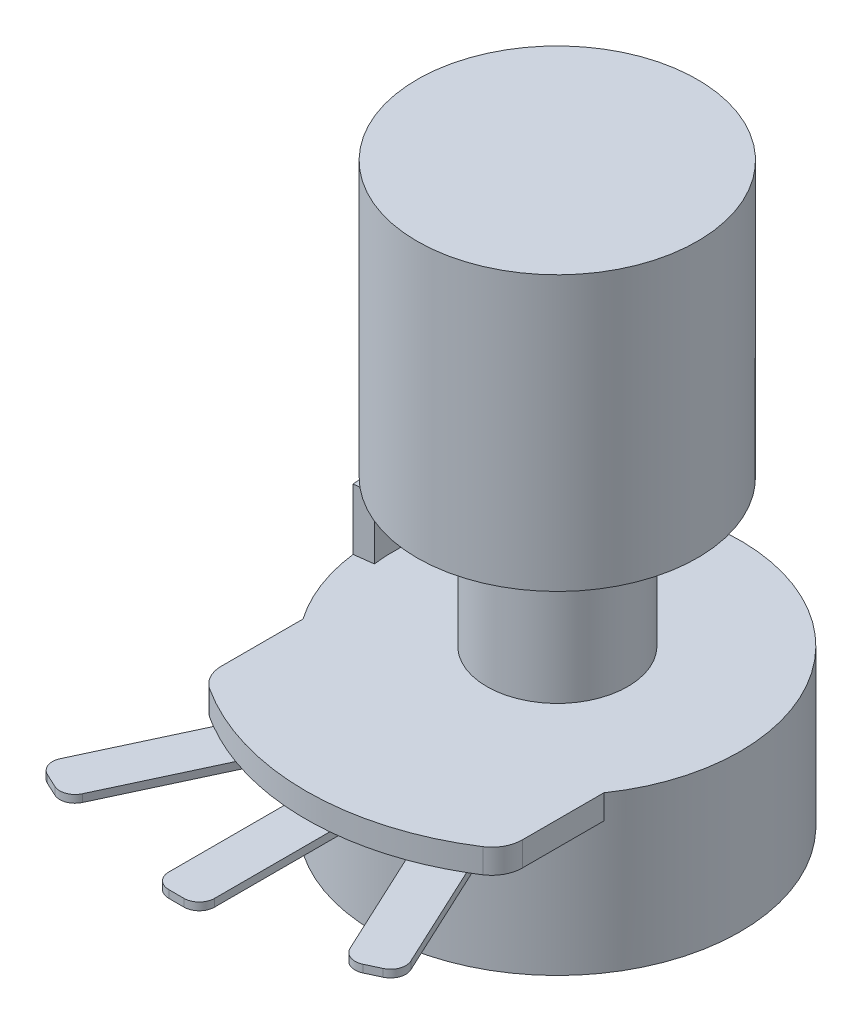
from build123d import *

# Parameters (mm, degrees)
SKETCH1_R                = 12
BOSS_EXTRUDE1_DEPTH      = 10.25
SKETCH4_W                = 19.75
SKETCH4_H                = 16.5
BOSS_EXTRUDE4_DEPTH      = 1.6
SKETCH5_OUTSIDE_W        = 33.728
SKETCH5_OUTSIDE_H        = 38.228
SKETCH5_OUTSIDE_R        = 16.5
CUT_EXTRUDE1_DEPTH       = 1.6
FILLET2_R                = 2
SKETCH6_W                = 3
SKETCH6_H                = 12.32415633
BOSS_EXTRUDE6_DEPTH      = 0.5
FILLET3_R                = 1
CIRPATTERN1_COUNT        = 2
CIRPATTERN1_ANGLE        = 25
FILLET3_OF_CIRPATTERN1_R = 1
CIRPATTERN2_COUNT        = 2
CIRPATTERN2_ANGLE        = 25
FILLET3_OF_CIRPATTERN2_R = 1
SKETCH2_R                = 4.625
BOSS_EXTRUDE2_DEPTH      = 9.6
SKETCH3_R                = 9.2
BOSS_EXTRUDE3_DEPTH      = 18
BOSS_EXTRUDE7_DEPTH      = 4


with BuildPart() as part:
    # Sketch1 → Boss-Extrude1 (new body)
    with BuildSketch(Plane(origin=(0, 0, 0), x_dir=(1, 0, 0), z_dir=(0, 1, 0))):
        Circle(SKETCH1_R)
    extrude(amount=BOSS_EXTRUDE1_DEPTH)

    # Sketch4 → Boss-Extrude4 (add)
    with BuildSketch(Plane(origin=(0, 10.25, 0), x_dir=(1, 0, 0), z_dir=(0, 1, 0))):
        with Locations((0, -8.25)):
            Rectangle(SKETCH4_W, SKETCH4_H)
    extrude(amount=-BOSS_EXTRUDE4_DEPTH)

    # Sketch5 outside → Cut-Extrude1 (cut)
    with BuildSketch(Plane(origin=(0, 10.25, 0), x_dir=(1, 0, 0), z_dir=(0, 1, 0))):
        with Locations((0, -2.25)):
            Rectangle(SKETCH5_OUTSIDE_W, SKETCH5_OUTSIDE_H)
        Circle(SKETCH5_OUTSIDE_R, mode=Mode.SUBTRACT)
    extrude(amount=-CUT_EXTRUDE1_DEPTH, mode=Mode.SUBTRACT)

    # Fillet2
    fillet2_edges = [part.edges().sort_by_distance(p)[0] for p in [
        (-9.875, 9.45, 13.218713061),
        (9.875, 9.45, 13.218713061),
    ]]
    fillet(fillet2_edges, radius=FILLET2_R)

    # Sketch6 → Boss-Extrude6 (add)
    with BuildSketch(Plane.XZ.offset(-8.65)):
        with Locations((0, 18.837921835)):
            Rectangle(SKETCH6_W, SKETCH6_H)
    boss_extrude6 = extrude(amount=BOSS_EXTRUDE6_DEPTH)

    # Fillet3
    fillet3_edges = [part.edges().sort_by_distance(p)[0] for p in [
        (-1.5, 8.4, 25),
        (1.5, 8.4, 25),
    ]]
    fillet(fillet3_edges, radius=FILLET3_R)

    # CirPattern1: Boss-Extrude6 ×2 about axis
    cirpattern1_axis = Axis((0, 0, 0), (0, 1, 0))
    for i in range(1, CIRPATTERN1_COUNT):
        add(boss_extrude6.rotate(cirpattern1_axis, i * CIRPATTERN1_ANGLE / (CIRPATTERN1_COUNT - 1)))

    # Fillet3 of CirPattern1
    fillet3_of_cirpattern1_edges = [part.edges().sort_by_distance(p)[0] for p in [
        (9.205994863, 8.4, 23.291622069),
        (11.924918224, 8.4, 22.023767283),
    ]]
    fillet(fillet3_of_cirpattern1_edges, radius=FILLET3_OF_CIRPATTERN1_R)

    # CirPattern2: Boss-Extrude6 ×2 about axis
    cirpattern2_axis = Axis((0, 0, 0), (0, -1, 0))
    for i in range(1, CIRPATTERN2_COUNT):
        add(boss_extrude6.rotate(cirpattern2_axis, i * CIRPATTERN2_ANGLE / (CIRPATTERN2_COUNT - 1)))

    # Fillet3 of CirPattern2
    fillet3_of_cirpattern2_edges = [part.edges().sort_by_distance(p)[0] for p in [
        (-11.924918224, 8.4, 22.023767283),
        (-9.205994863, 8.4, 23.291622069),
    ]]
    fillet(fillet3_of_cirpattern2_edges, radius=FILLET3_OF_CIRPATTERN2_R)

    # Sketch2 → Boss-Extrude2 (add)
    with BuildSketch(Plane(origin=(0, 10.25, 0), x_dir=(1, 0, 0), z_dir=(0, 1, 0))):
        Circle(SKETCH2_R)
    extrude(amount=BOSS_EXTRUDE2_DEPTH)

    # Sketch3 → Boss-Extrude3 (add)
    with BuildSketch(Plane(origin=(0, 19.85, 0), x_dir=(1, 0, 0), z_dir=(0, 1, 0))):
        Circle(SKETCH3_R)
    extrude(amount=BOSS_EXTRUDE3_DEPTH)

    # Sketch7 → Boss-Extrude7 (add)
    with BuildSketch(Plane(origin=(0, 10.25, 0), x_dir=(1, 0, 0), z_dir=(0, 1, 0))):
        with BuildLine():
            Line((-11.9058809, 1.5), (-10.665684973, 1.34375))
            ThreePointArc((-10.665684973, 1.34375), (-10.75, 0), (-10.665684973, -1.34375))
            Line((-10.665684973, -1.34375), (-11.9058809, -1.5))
            ThreePointArc((-11.9058809, -1.5), (-12, 0), (-11.9058809, 1.5))
        make_face()
    extrude(amount=BOSS_EXTRUDE7_DEPTH)


solid = part.part
